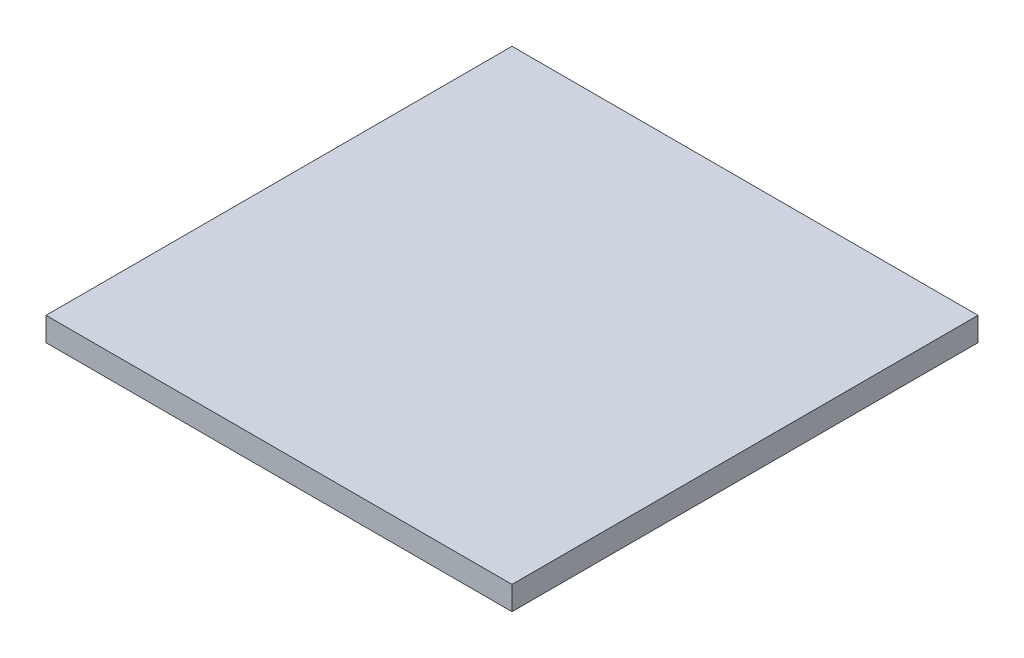
from build123d import *

# Parameters (mm, degrees)
SKETCH1_W           = 29.5
SKETCH1_H           = 29.5
BOSS_EXTRUDE1_DEPTH = 1.5


with BuildPart() as part:
    # Sketch1 → Boss-Extrude1 (new body)
    with BuildSketch(Plane(origin=(0, 0, 0), x_dir=(1, 0, 0), z_dir=(0, 1, 0))):
        with Locations((-7.453180212, 4.899293286)):
            Rectangle(SKETCH1_W, SKETCH1_H)
    extrude(amount=BOSS_EXTRUDE1_DEPTH)


solid = part.part
